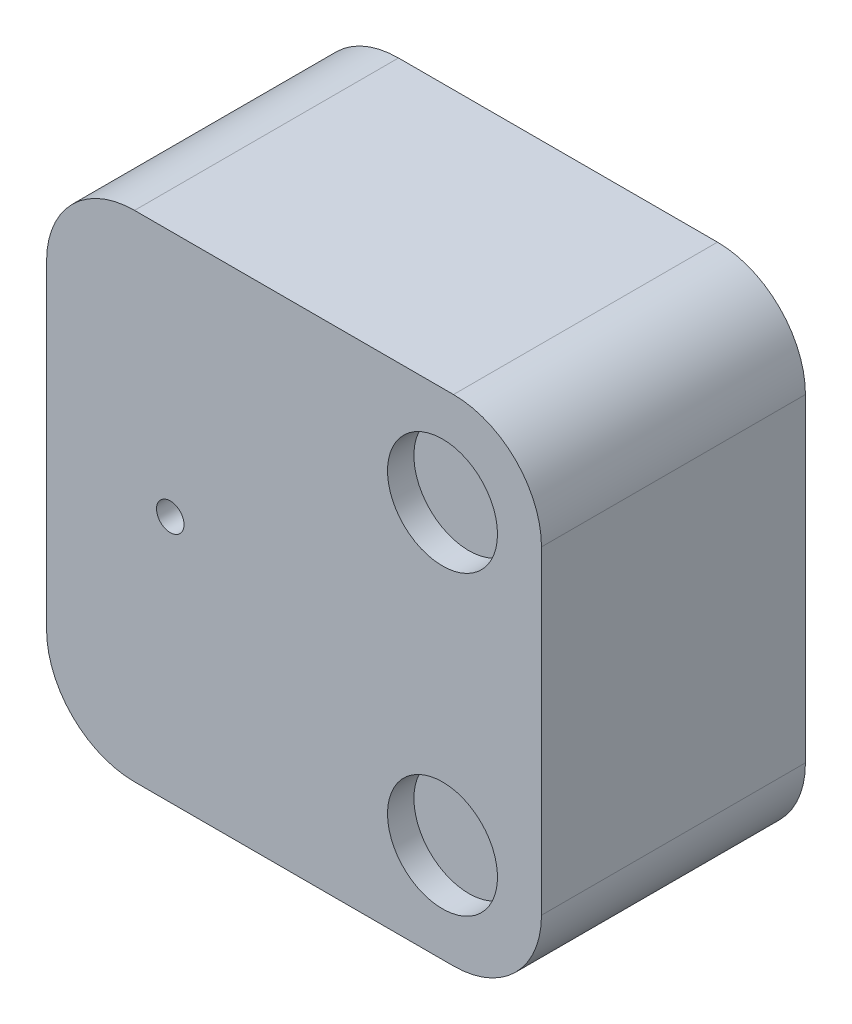
from build123d import *

# Parameters (mm, degrees)
ESQUISSE1_W             = 180
ESQUISSE1_H             = 180
BOSS_EXTRU_1_DEPTH      = 96
CONG_1_R                = 32
ESQUISSE2_R             = 20
ESQUISSE2_R_2           = 5
ENL_V_MAT_EXTRU_1_DEPTH = 9.6


with BuildPart() as part:
    # Esquisse1 → Boss.-Extru.1 (new body)
    with BuildSketch(Plane.XY):
        Rectangle(ESQUISSE1_W, ESQUISSE1_H)
    extrude(amount=BOSS_EXTRU_1_DEPTH)

    # Congé1
    cong_1_edges = [part.edges().sort_by_distance(p)[0] for p in [
        (-90, 90, 48),
        (-90, -90, 48),
        (90, -90, 48),
        (90, 90, 48),
    ]]
    fillet(cong_1_edges, radius=CONG_1_R)

    # Esquisse2 → Enlèv. mat.-Extru.1 (cut)
    with BuildSketch(Plane.XY.offset(96)):
        with Locations((54, 54)):
            Circle(ESQUISSE2_R)
        with Locations((54, -54)):
            Circle(ESQUISSE2_R)
        with Locations((-45, 0)):
            Circle(ESQUISSE2_R_2)
    extrude(amount=-ENL_V_MAT_EXTRU_1_DEPTH, mode=Mode.SUBTRACT)


solid = part.part
